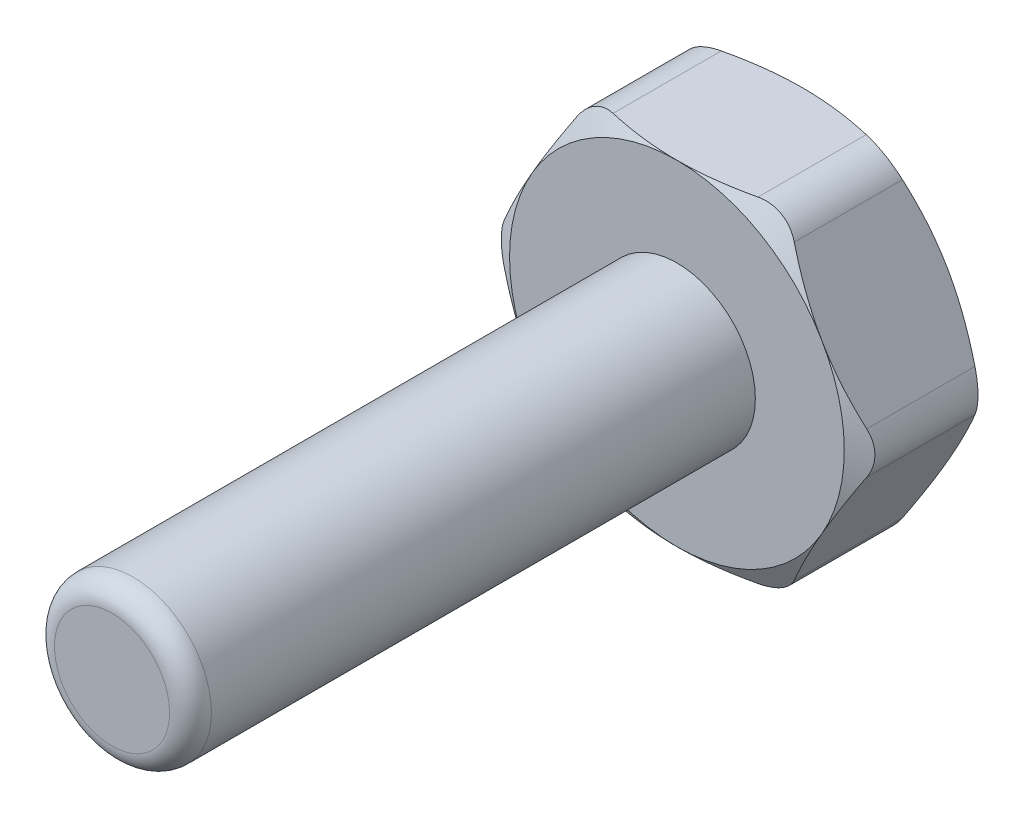
from build123d import *

# Parameters (mm, degrees)
BOSS_EXTRUDE2_DEPTH     = 1.5
SKETCH5_OUTSIDE_W       = 65.716
SKETCH5_OUTSIDE_H       = 64.478
SKETCH5_OUTSIDE_R       = 4
CUT_EXTRUDE1_DEPTH      = 15
CUT_EXTRUDE1_DRAFT      = -60
MIRROR1_COPY_1_SKETCH_W = 65.716
MIRROR1_COPY_1_SKETCH_H = 64.478
MIRROR1_COPY_1_SKETCH_R = 4
MIRROR1_COPY_1_DEPTH    = 15
MIRROR1_COPY_1_DRAFT    = -60
SKETCH4_3_R             = 1.875
BOSS_EXTRUDE3_DEPTH     = 15
FILLET1_R               = 1
FILLET2_R               = 0.5


with BuildPart() as part:
    # Sketch4 → Boss-Extrude2 (new, symmetric)
    with BuildSketch(Plane.XY):
        Polygon((2.309401077, 4), (-2.309401077, 4), (-4.618802154, 0), (-2.309401077, -4), (2.309401077, -4), (4.618802154, 0), align=None)
    extrude(amount=BOSS_EXTRUDE2_DEPTH, both=True)


with BuildPart() as cut_extrude1_tool:
    # Sketch5 outside → Cut-Extrude1 (with draft: the straight prism first)
    with BuildSketch(Plane.XY.offset(1.5)):
        Rectangle(SKETCH5_OUTSIDE_W, SKETCH5_OUTSIDE_H)
        Circle(SKETCH5_OUTSIDE_R, mode=Mode.SUBTRACT)
    extrude(amount=-CUT_EXTRUDE1_DEPTH)
    # Cut-Extrude1: the draft: its side faces are tilted about the plane it starts from
    cut_extrude1_sides = [cut_extrude1_tool.faces().sort_by_distance(p)[0] for p in [
        (0, -32.239, -6),
        (32.858, 0, -6),
        (0, 32.239, -6),
        (-32.858, 0, -6),
        (-4, 0, -6),
    ]]
    draft(cut_extrude1_sides, Plane.XY.offset(1.5), CUT_EXTRUDE1_DRAFT)


with BuildPart() as part_1:
    add(part.part)

    # Cut-Extrude1: cut by cut_extrude1_tool
    add(cut_extrude1_tool.part, mode=Mode.SUBTRACT)


with BuildPart() as mirror1_copy_1_tool:
    # Mirror1 copy 1 sketch → Mirror1 copy 1 (with draft: the straight prism first)
    with BuildSketch(Plane(origin=(0, 0, -1.5), x_dir=(1, 0, 0), z_dir=(0, 0, -1))):
        Rectangle(MIRROR1_COPY_1_SKETCH_W, MIRROR1_COPY_1_SKETCH_H)
        Circle(MIRROR1_COPY_1_SKETCH_R, mode=Mode.SUBTRACT)
    extrude(amount=-MIRROR1_COPY_1_DEPTH)
    # Mirror1 copy 1: the draft: its side faces are tilted about the plane it starts from
    mirror1_copy_1_sides = [mirror1_copy_1_tool.faces().sort_by_distance(p)[0] for p in [
        (0, -32.239, 6),
        (32.858, 0, 6),
        (0, 32.239, 6),
        (-32.858, 0, 6),
        (-4, 0, 6),
    ]]
    draft(mirror1_copy_1_sides, Plane(origin=(0, 0, -1.5), x_dir=(1, 0, 0), z_dir=(0, 0, -1)), MIRROR1_COPY_1_DRAFT)


with BuildPart() as part_2:
    add(part_1.part)

    # Mirror1 copy 1: cut by mirror1_copy_1_tool
    add(mirror1_copy_1_tool.part, mode=Mode.SUBTRACT)

    # Sketch4_3 → Boss-Extrude3 (add)
    with BuildSketch(Plane.XY):
        Circle(SKETCH4_3_R)
    extrude(amount=BOSS_EXTRUDE3_DEPTH)

    # Fillet1
    fillet1_edges = [part_2.edges().sort_by_distance(p)[0] for p in [
        (4.618802154, 0, 0),
        (2.309401077, -4, 0),
        (-2.309401077, -4, 0),
        (-4.618802154, 0, 0),
        (-2.309401077, 4, 0),
        (2.309401077, 4, 0),
    ]]
    fillet(fillet1_edges, radius=FILLET1_R)

    # Fillet2
    fillet2_edges = [part_2.edges().sort_by_distance(p)[0] for p in [
        (-1.875, 0, 15),
    ]]
    fillet(fillet2_edges, radius=FILLET2_R)


solid = part_2.part
